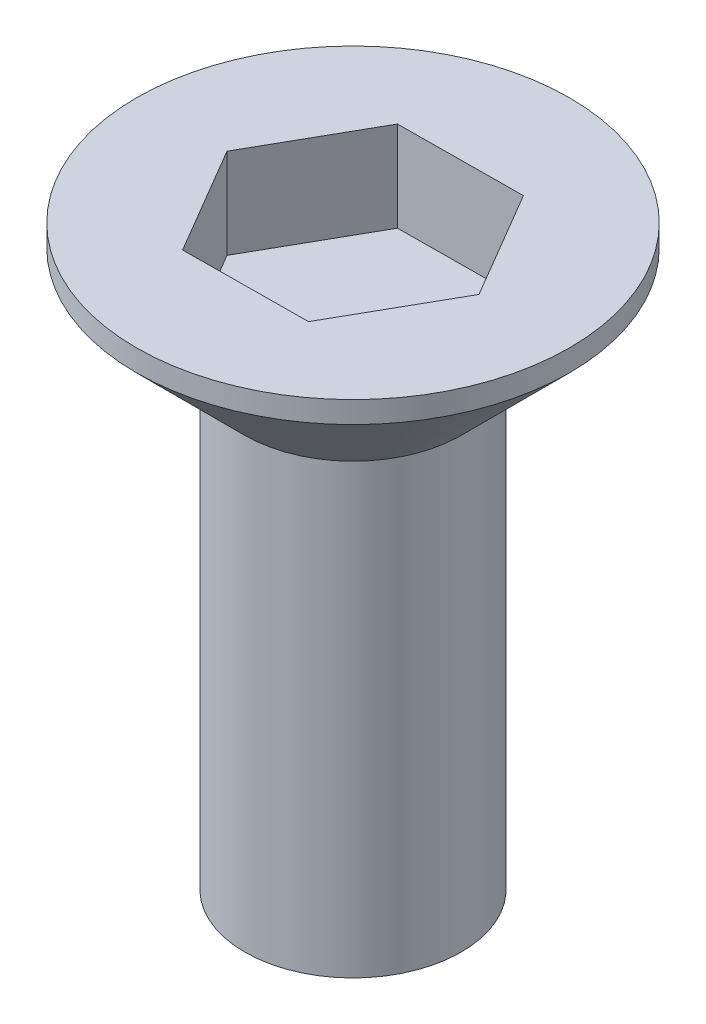
from build123d import *

# Parameters (mm, degrees)
CUT_EXTRUDE_1_DEPTH = 2.5


with BuildPart() as part:
    # Эскиз1 → Повернуть1 (revolve)
    with BuildSketch(Plane.XY):
        Polygon((0, 0), (3, 0), (3, 12.4), (6, 15.4), (6, 16), (0, 16), align=None)
    revolve(axis=Axis((0, 68.644575989, 0), (0, -1, 0)))

    # Эскиз2 → Вырез-Вытянуть1 (cut)
    with BuildSketch(Plane(origin=(0, 16, 0), x_dir=(1, 0, 0), z_dir=(0, 1, 0))):
        Polygon((1.755265403, -2.986476748), (3.463997433, 0.026866056), (1.708732029, 3.013342804), (-1.755265403, 2.986476748), (-3.463997433, -0.026866056), (-1.708732029, -3.013342804), align=None)
    extrude(amount=-CUT_EXTRUDE_1_DEPTH, mode=Mode.SUBTRACT)


solid = part.part
